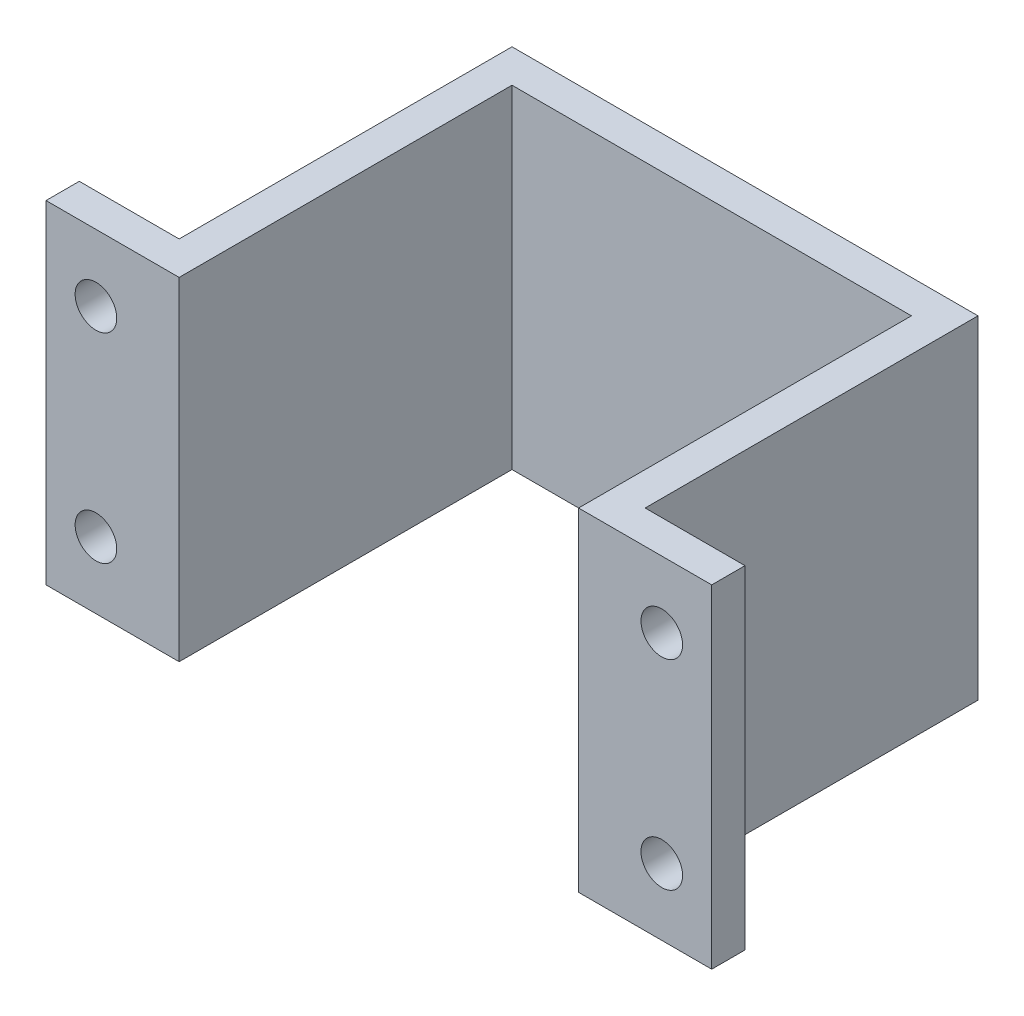
from build123d import *

# Parameters (mm, degrees)
EXTRUDE_1_DEPTH          = 10
HOLE_WIZARD_M1_6_1_D     = 1.25
HOLE_WIZARD_M1_6_1_DEPTH = 4.95
HOLE_WIZARD_M1_6_1_TIP   = 0.375537887


with BuildPart() as part:
    # 草图2 → 凸台-拉伸1 (new body)
    with BuildSketch(Plane(origin=(0, 0, 0), x_dir=(1, 0, 0), z_dir=(0, 1, 0))):
        Polygon((7, 11), (-7, 11), (-7, 1), (-10, 1), (-10, 0), (-6, 0), (-6, 10), (6, 10), (6, 0), (10, 0), (10, 1), (7, 1), align=None)
    extrude(amount=EXTRUDE_1_DEPTH)

    # M1.6 螺纹孔1
    with Locations(Plane(origin=(0, 0, -1), x_dir=(-1, 0, 0), z_dir=(0, 0, -1))):
        with Locations((-8.5, 8), (8.5, 8), (8.5, 2), (-8.5, 2)):
            Hole(HOLE_WIZARD_M1_6_1_D / 2, depth=HOLE_WIZARD_M1_6_1_DEPTH)
            with Locations((0, 0, -(HOLE_WIZARD_M1_6_1_DEPTH + HOLE_WIZARD_M1_6_1_TIP / 2))):  # 118° drill point
                Cone(0, HOLE_WIZARD_M1_6_1_D / 2, HOLE_WIZARD_M1_6_1_TIP, mode=Mode.SUBTRACT)


solid = part.part
